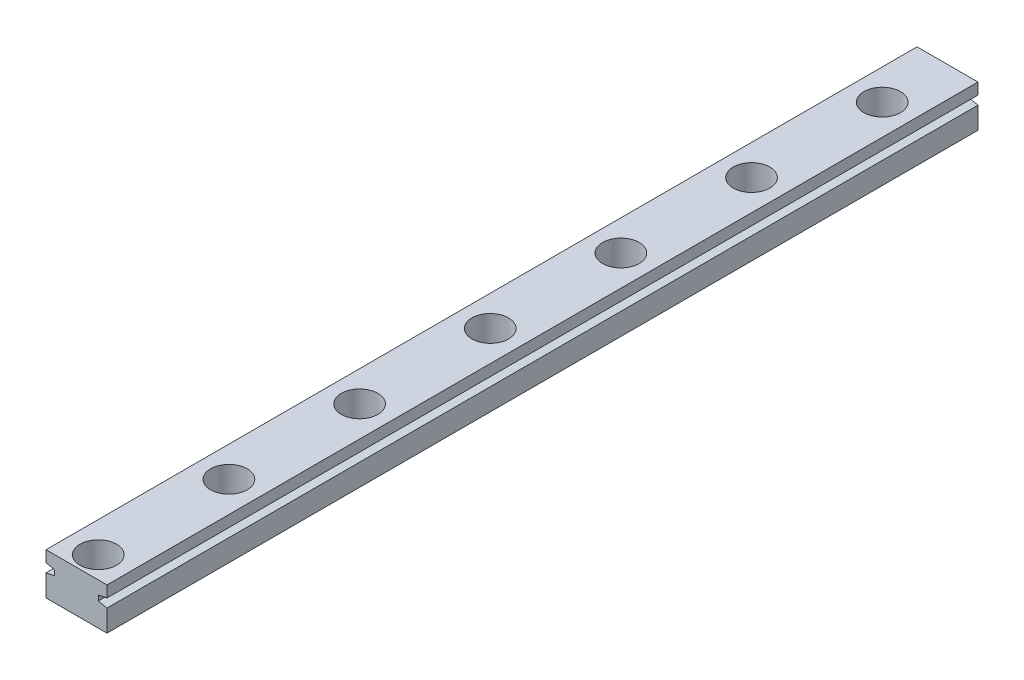
from build123d import *

# Parameters (mm, degrees)
SKETCH_1_W          = 7
SKETCH_1_H          = 4.8
EXTRUDE_1_DEPTH     = 100
SKETCH_2_R          = 1.2
CUT_EXTRUDE_1_DEPTH = 5.8
SKETCH_3_R          = 2.1
CUT_EXTRUDE_2_DEPTH = 3.5
CUT_EXTRUDE_3_DEPTH = 101


with BuildPart() as part:
    # 草图1 → 凸台-拉伸1 (new body)
    with BuildSketch(Plane.XY):
        Rectangle(SKETCH_1_W, SKETCH_1_H)
    extrude(amount=EXTRUDE_1_DEPTH)

    # 草图2 → 切除-拉伸1 (cut, through all)
    with BuildSketch(Plane(origin=(0, 2.4, 0), x_dir=(1, 0, 0), z_dir=(0, 1, 0))):
        with Locations((0, -7.5)):
            Circle(SKETCH_2_R)
        with Locations((0, -22.5)):
            Circle(SKETCH_2_R)
        with Locations((0, -37.5)):
            Circle(SKETCH_2_R)
        with Locations((0, -52.5)):
            Circle(SKETCH_2_R)
        with Locations((0, -67.5)):
            Circle(SKETCH_2_R)
        with Locations((0, -82.5)):
            Circle(SKETCH_2_R)
        with Locations((0, -97.5)):
            Circle(SKETCH_2_R)
        with Locations((0, -112.5)):
            Circle(SKETCH_2_R)
        with Locations((0, -127.5)):
            Circle(SKETCH_2_R)
        with Locations((0, -142.5)):
            Circle(SKETCH_2_R)
        with Locations((0, -157.5)):
            Circle(SKETCH_2_R)
        with Locations((0, -172.5)):
            Circle(SKETCH_2_R)
        with Locations((0, -187.5)):
            Circle(SKETCH_2_R)
        with Locations((0, -202.5)):
            Circle(SKETCH_2_R)
        with Locations((0, -217.5)):
            Circle(SKETCH_2_R)
        with Locations((0, -232.5)):
            Circle(SKETCH_2_R)
        with Locations((0, -247.5)):
            Circle(SKETCH_2_R)
        with Locations((0, -262.5)):
            Circle(SKETCH_2_R)
        with Locations((0, -277.5)):
            Circle(SKETCH_2_R)
        with Locations((0, -292.5)):
            Circle(SKETCH_2_R)
    extrude(amount=-CUT_EXTRUDE_1_DEPTH, mode=Mode.SUBTRACT)

    # 草图3 → 切除-拉伸2 (cut)
    with BuildSketch(Plane(origin=(0, 2.4, 0), x_dir=(1, 0, 0), z_dir=(0, 1, 0))):
        with Locations((0, -7.5)):
            Circle(SKETCH_3_R)
        with Locations((0, -22.5)):
            Circle(SKETCH_3_R)
        with Locations((0, -37.5)):
            Circle(SKETCH_3_R)
        with Locations((0, -52.5)):
            Circle(SKETCH_3_R)
        with Locations((0, -67.5)):
            Circle(SKETCH_3_R)
        with Locations((0, -82.5)):
            Circle(SKETCH_3_R)
        with Locations((0, -97.5)):
            Circle(SKETCH_3_R)
        with Locations((0, -112.5)):
            Circle(SKETCH_3_R)
        with Locations((0, -127.5)):
            Circle(SKETCH_3_R)
        with Locations((0, -142.5)):
            Circle(SKETCH_3_R)
        with Locations((0, -157.5)):
            Circle(SKETCH_3_R)
        with Locations((0, -172.5)):
            Circle(SKETCH_3_R)
        with Locations((0, -187.5)):
            Circle(SKETCH_3_R)
        with Locations((0, -202.5)):
            Circle(SKETCH_3_R)
        with Locations((0, -217.5)):
            Circle(SKETCH_3_R)
        with Locations((0, -232.5)):
            Circle(SKETCH_3_R)
        with Locations((0, -247.5)):
            Circle(SKETCH_3_R)
        with Locations((0, -262.5)):
            Circle(SKETCH_3_R)
        with Locations((0, -277.5)):
            Circle(SKETCH_3_R)
        with Locations((0, -292.5)):
            Circle(SKETCH_3_R)
    extrude(amount=-CUT_EXTRUDE_2_DEPTH, mode=Mode.SUBTRACT)

    # 草图4 → 切除-拉伸3 (cut, through all)
    with BuildSketch(Plane(origin=(0, 0, 0), x_dir=(-1, 0, 0), z_dir=(0, 0, -1))):
        Polygon((3.5, 1.1), (2.5, 0.9), (2.5, 0.3), (3.5, 0.1), align=None)
        Polygon((-3.5, 1.1), (-2.5, 0.9), (-2.5, 0.3), (-3.5, 0.1), align=None)
    extrude(amount=-CUT_EXTRUDE_3_DEPTH, mode=Mode.SUBTRACT)


solid = part.part
